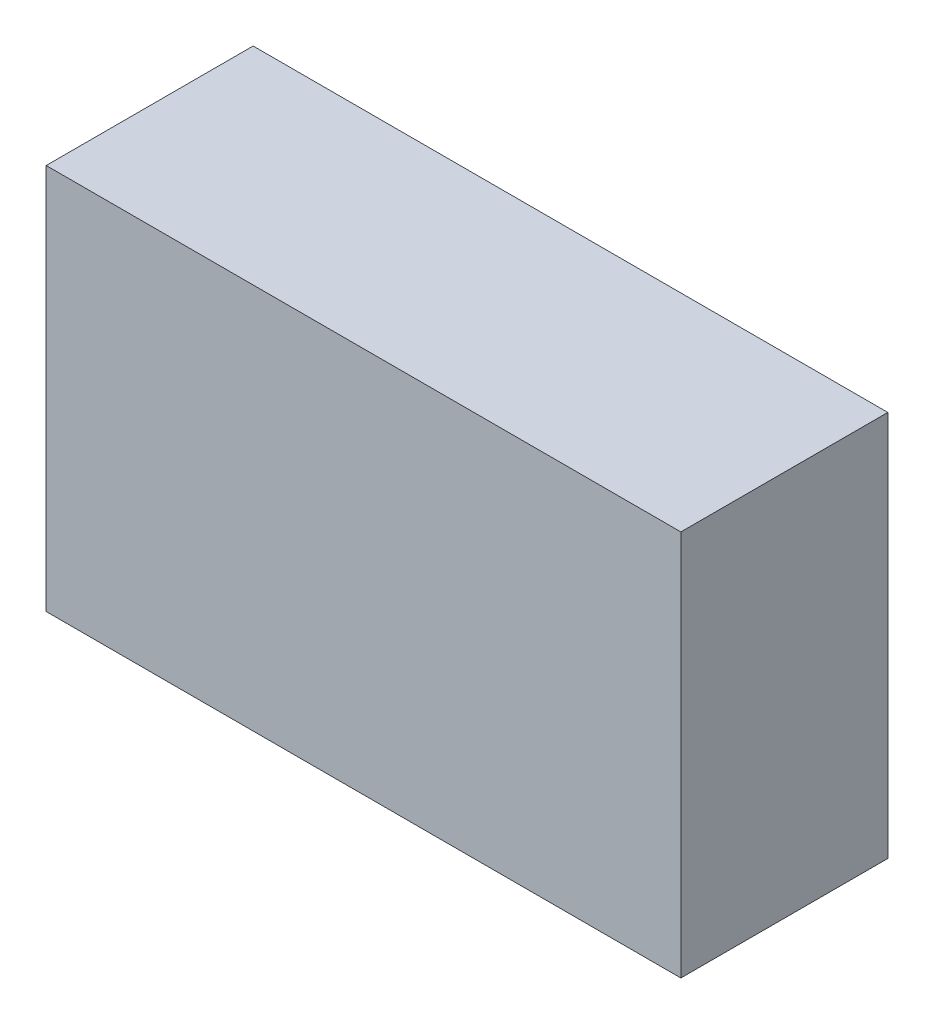
from build123d import *

# Parameters (mm, degrees)
SKETCH1_W           = 46
SKETCH1_H           = 28
BOSS_EXTRUDE1_DEPTH = 15


with BuildPart() as part:
    # Sketch1 → Boss-Extrude1 (new body)
    with BuildSketch(Plane.XY):
        with Locations((23, 14)):
            Rectangle(SKETCH1_W, SKETCH1_H)
    extrude(amount=BOSS_EXTRUDE1_DEPTH)


solid = part.part
